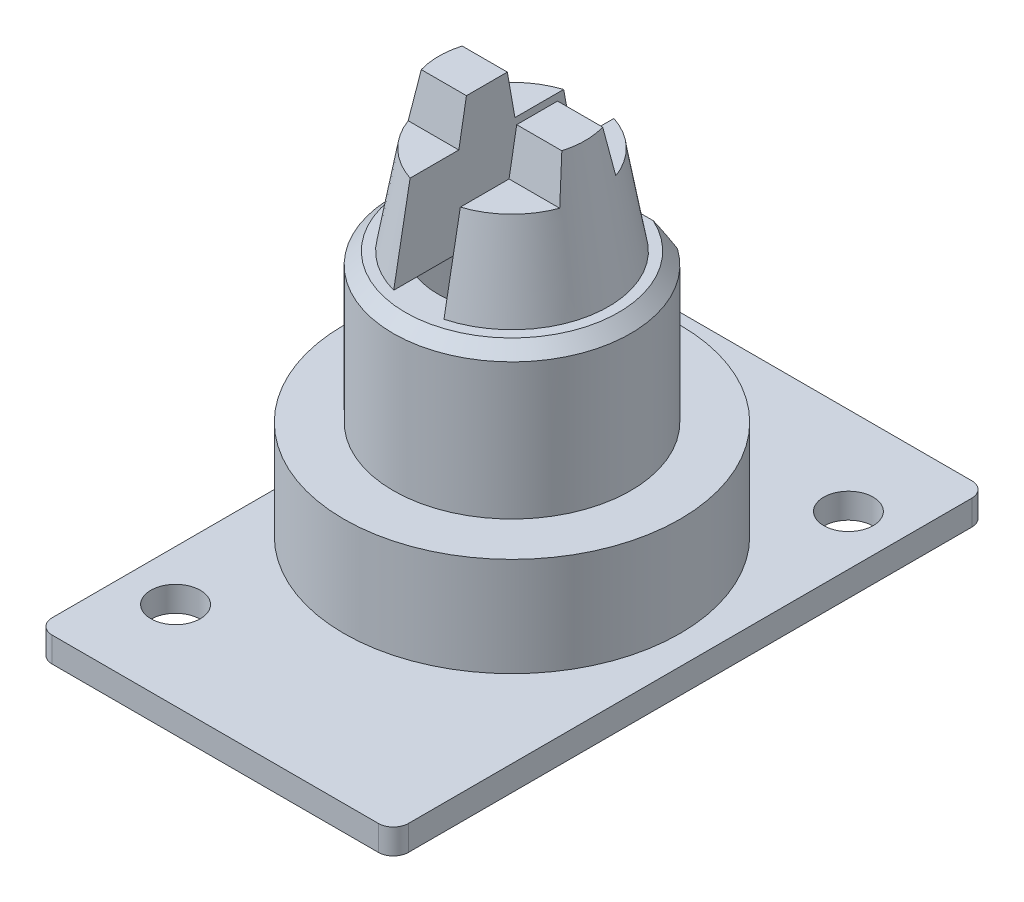
from build123d import *

# Parameters (mm, degrees)
BOSS_EXTRUDE1_DEPTH     = 1.27
CUT_EXTRUDE1_DEPTH      = 6.985
CUT_EXTRUDE1_DEPTH_BACK = 6.985
SKETCH3_W               = 12
SKETCH3_H               = 12
CUT_EXTRUDE2_DEPTH      = 12
CUT_EXTRUDE2_DEPTH_BACK = 12
CUT_EXTRUDE3_DEPTH      = 1.27
CUT_EXTRUDE3_DEPTH_BACK = 1.27
SKETCH6_W               = 9.7536
SKETCH6_H               = 7.3914
CUT_EXTRUDE4_DEPTH      = 2.54
CUT_EXTRUDE4_DEPTH_BACK = 2.54
SKETCH7_R               = 1.25
CUT_EXTRUDE5_DEPTH      = 2.54
CUT_EXTRUDE5_DEPTH_BACK = 2.54
SKETCH8_R               = 1.25


with BuildPart() as part:
    # Sketch1 → Boss-Extrude1 (new body)
    with BuildSketch(Plane(origin=(0, 0, 0), x_dir=(1, 0, 0), z_dir=(0, 1, 0))):
        with BuildLine():
            Line((-9.0043, 14.2367), (-9.0043, -14.2367))
            ThreePointArc((-9.0043, -14.2367), (-8.781115367, -14.775515367), (-8.2423, -14.9987))
            Line((-8.2423, -14.9987), (8.2423, -14.9987))
            ThreePointArc((8.2423, -14.9987), (8.781115367, -14.775515367), (9.0043, -14.2367))
            Line((9.0043, -14.2367), (9.0043, 14.2367))
            ThreePointArc((9.0043, 14.2367), (8.781115367, 14.775515367), (8.2423, 14.9987))
            Line((8.2423, 14.9987), (-8.2423, 14.9987))
            ThreePointArc((-8.2423, 14.9987), (-8.781115367, 14.775515367), (-9.0043, 14.2367))
        make_face()
    extrude(amount=BOSS_EXTRUDE1_DEPTH)

    # Sketch2 → Revolve1 (revolve)
    with BuildSketch(Plane(origin=(0, 0, 0), x_dir=(0, 0, -1), z_dir=(1, 0, 0))):
        Polygon((3.7592, 14.7066), (3.7592, 0.9398), (6.589242136, 0.9398), (6.126999938, 2.2098), (8.4963, 2.2098), (8.4963, 7.2136), (5.999999938, 7.2136), (5.999999938, 14.093100062), (5.3865, 14.7066), align=None)
    revolve(axis=Axis((0, 0.9398, 0), (0, 1, 0)))

    # Sketch3 → Cut-Extrude1 (cut, two sides: drawn at the far end of the back side and taken through both)
    with BuildSketch(Plane(origin=(0, 14.7066, 0), x_dir=(1, 0, 0), z_dir=(0, 1, 0)).offset(-CUT_EXTRUDE1_DEPTH_BACK)):
        with Locations((0, 10.8966)):
            Rectangle(SKETCH3_W, SKETCH3_H)
    extrude(amount=CUT_EXTRUDE1_DEPTH + CUT_EXTRUDE1_DEPTH_BACK, mode=Mode.SUBTRACT)

    # Sketch4 → Revolve2 (revolve)
    with BuildSketch(Plane(origin=(0, 0, 0), x_dir=(0, 0, -1), z_dir=(1, 0, 0))):
        Polygon((0, 22.098), (3.573496755, 22.098), (4.8768, 14.7066), (0, 14.7066), align=None)
    revolve(axis=Axis((0, 14.7066, 0), (0, 1, 0)))

    # Sketch5 → Cut-Extrude2 (cut, two sides: drawn at the far end of the back side and taken through both)
    with BuildSketch(Plane(origin=(0, 0, 0), x_dir=(0, 0, -1), z_dir=(1, 0, 0)).offset(-CUT_EXTRUDE2_DEPTH_BACK)):
        Polygon((-4.8768, 23.6982), (-4.08406916, 19.2024), (-1.418134328, 19.2024), (-1.032965672, 21.3868), (1.032965672, 21.3868), (1.418134328, 19.2024), (4.08406916, 19.2024), (4.8768, 23.6982), align=None)
    extrude(amount=CUT_EXTRUDE2_DEPTH + CUT_EXTRUDE2_DEPTH_BACK, mode=Mode.SUBTRACT)

    # Sketch6 → Cut-Extrude3 (cut, two sides: drawn at the far end of the back side and taken through both)
    with BuildSketch(Plane(origin=(0, 0, 0), x_dir=(0, 0, -1), z_dir=(1, 0, 0)).offset(-CUT_EXTRUDE3_DEPTH_BACK)):
        with Locations((0, 18.4023)):
            Rectangle(SKETCH6_W, SKETCH6_H)
    extrude(amount=CUT_EXTRUDE3_DEPTH + CUT_EXTRUDE3_DEPTH_BACK, mode=Mode.SUBTRACT)

    # Sketch7 → Cut-Extrude4 (cut, two sides: drawn at the far end of the back side and taken through both)
    with BuildSketch(Plane(origin=(0, 0, 0), x_dir=(1, 0, 0), z_dir=(0, 1, 0)).offset(-CUT_EXTRUDE4_DEPTH_BACK)):
        with Locations((6.4643, 10.541)):
            Circle(SKETCH7_R)
    extrude(amount=CUT_EXTRUDE4_DEPTH + CUT_EXTRUDE4_DEPTH_BACK, mode=Mode.SUBTRACT)

    # Sketch8 → Cut-Extrude5 (cut, two sides: drawn at the far end of the back side and taken through both)
    with BuildSketch(Plane(origin=(0, 0, 0), x_dir=(1, 0, 0), z_dir=(0, 1, 0)).offset(-CUT_EXTRUDE5_DEPTH_BACK)):
        with Locations((-6.4643, -10.541)):
            Circle(SKETCH8_R)
    extrude(amount=CUT_EXTRUDE5_DEPTH + CUT_EXTRUDE5_DEPTH_BACK, mode=Mode.SUBTRACT)


solid = part.part
